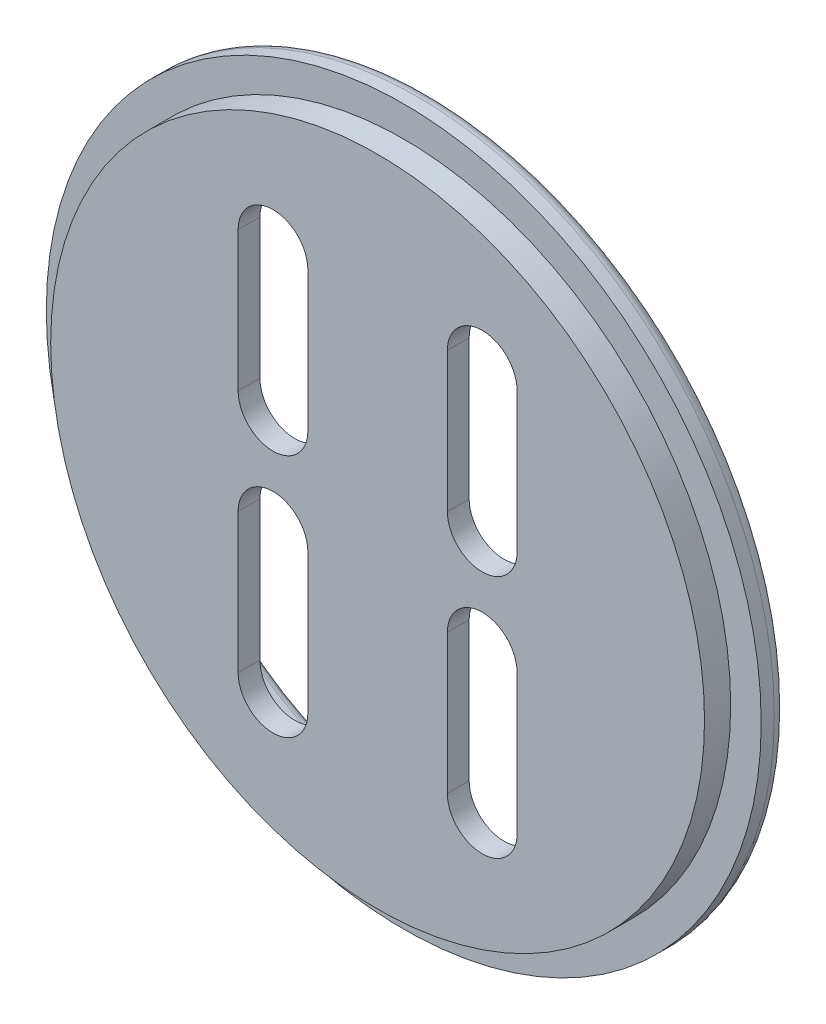
from build123d import *

# Parameters (mm, degrees)
SKETCH1_R           = 41
BOSS_EXTRUDE1_DEPTH = 3
SKETCH2_R           = 37.5
BOSS_EXTRUDE4_DEPTH = 3
SKETCH5_R           = 31.5
CUT_EXTRUDE3_DEPTH  = 3.5
CUT_EXTRUDE6_DEPTH  = 3
FILLET3_R           = 1
FILLET4_R           = 1.5
FILLET5_R           = 1


with BuildPart() as part:
    # Sketch1 → Boss-Extrude1 (new body)
    with BuildSketch(Plane.XY):
        Circle(SKETCH1_R)
    extrude(amount=BOSS_EXTRUDE1_DEPTH)

    # Sketch2 → Boss-Extrude4 (add)
    with BuildSketch(Plane.XY.offset(3)):
        Circle(SKETCH2_R)
    extrude(amount=BOSS_EXTRUDE4_DEPTH)

    # Sketch5 → Cut-Extrude3 (cut)
    with BuildSketch(Plane(origin=(0, 0, 0), x_dir=(-1, 0, 0), z_dir=(0, 0, -1))):
        Circle(SKETCH5_R)
    extrude(amount=-CUT_EXTRUDE3_DEPTH, mode=Mode.SUBTRACT)

    # Sketch6 → Cut-Extrude6 (cut)
    with BuildSketch(Plane(origin=(0, 0, 3.5), x_dir=(-1, 0, 0), z_dir=(0, 0, -1))):
        with BuildLine():
            Line((-16, 6), (-16, 22))
            ThreePointArc((-16, 22), (-12, 26), (-8, 22))
            Line((-8, 22), (-8, 6))
            ThreePointArc((-8, 6), (-12, 2), (-16, 6))
        make_face()
        with BuildLine():
            Line((16, 6), (16, 22))
            ThreePointArc((16, 22), (12, 26), (8, 22))
            Line((8, 22), (8, 6))
            ThreePointArc((8, 6), (12, 2), (16, 6))
        make_face()
        with BuildLine():
            Line((16, -6), (16, -22))
            ThreePointArc((16, -22), (12, -26), (8, -22))
            Line((8, -22), (8, -6))
            ThreePointArc((8, -6), (12, -2), (16, -6))
        make_face()
        with BuildLine():
            Line((-16, -6), (-16, -22))
            ThreePointArc((-16, -22), (-12, -26), (-8, -22))
            Line((-8, -22), (-8, -6))
            ThreePointArc((-8, -6), (-12, -2), (-16, -6))
        make_face()
    extrude(amount=-CUT_EXTRUDE6_DEPTH, mode=Mode.SUBTRACT)

    # Fillet3
    fillet3_edges = [part.edges().sort_by_distance(p)[0] for p in [
        (31.5, 0, 0),
    ]]
    fillet(fillet3_edges, radius=FILLET3_R)

    # Fillet4
    fillet4_edges = [part.edges().sort_by_distance(p)[0] for p in [
        (-41, 0, 0),
    ]]
    fillet(fillet4_edges, radius=FILLET4_R)

    # Fillet5
    fillet5_edges = [part.edges().sort_by_distance(p)[0] for p in [
        (31.5, 0, 3.5),
    ]]
    fillet(fillet5_edges, radius=FILLET5_R)


solid = part.part
